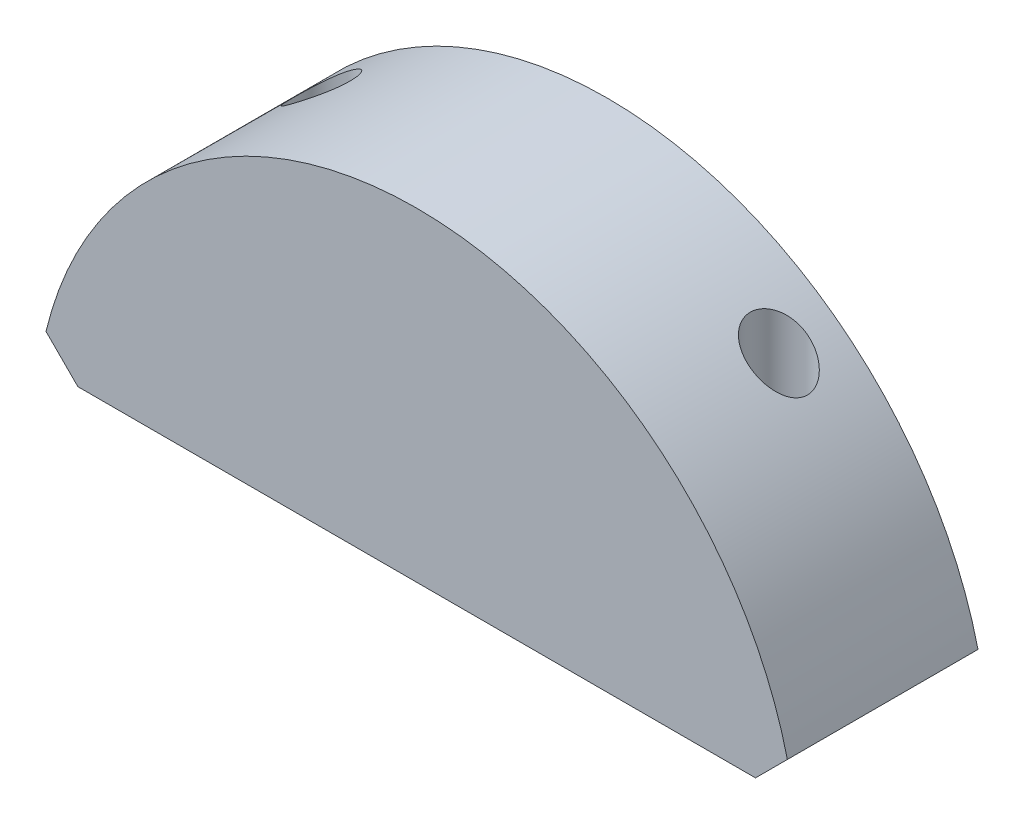
from build123d import *

# Parameters (mm, degrees)
EXTRUSION1_DEPTH = 10
ESQUISSE2_R      = 1.5
EXTRUSION2_DEPTH = 18


with BuildPart() as part:
    # Esquisse1 → Extrusion1 (new body)
    with BuildSketch(Plane.XY):
        with BuildLine():
            Line((17.773719933, 3), (-17.773719933, 3))
            Line((-17.773719933, 3), (-19.446474381, 4.672754448))
            ThreePointArc((-19.446474381, 4.672754448), (0, 20), (19.446474381, 4.672754448))
            Line((19.446474381, 4.672754448), (17.773719933, 3))
        make_face()
    extrude(amount=EXTRUSION1_DEPTH)

    # Esquisse2 → Extrusion2 (cut, through all)
    with BuildSketch(Plane.XZ.offset(-3)):
        with Locations((-12, 3)):
            Circle(ESQUISSE2_R)
        with Locations((12, 3)):
            Circle(ESQUISSE2_R)
    extrude(amount=-EXTRUSION2_DEPTH, mode=Mode.SUBTRACT)


solid = part.part
